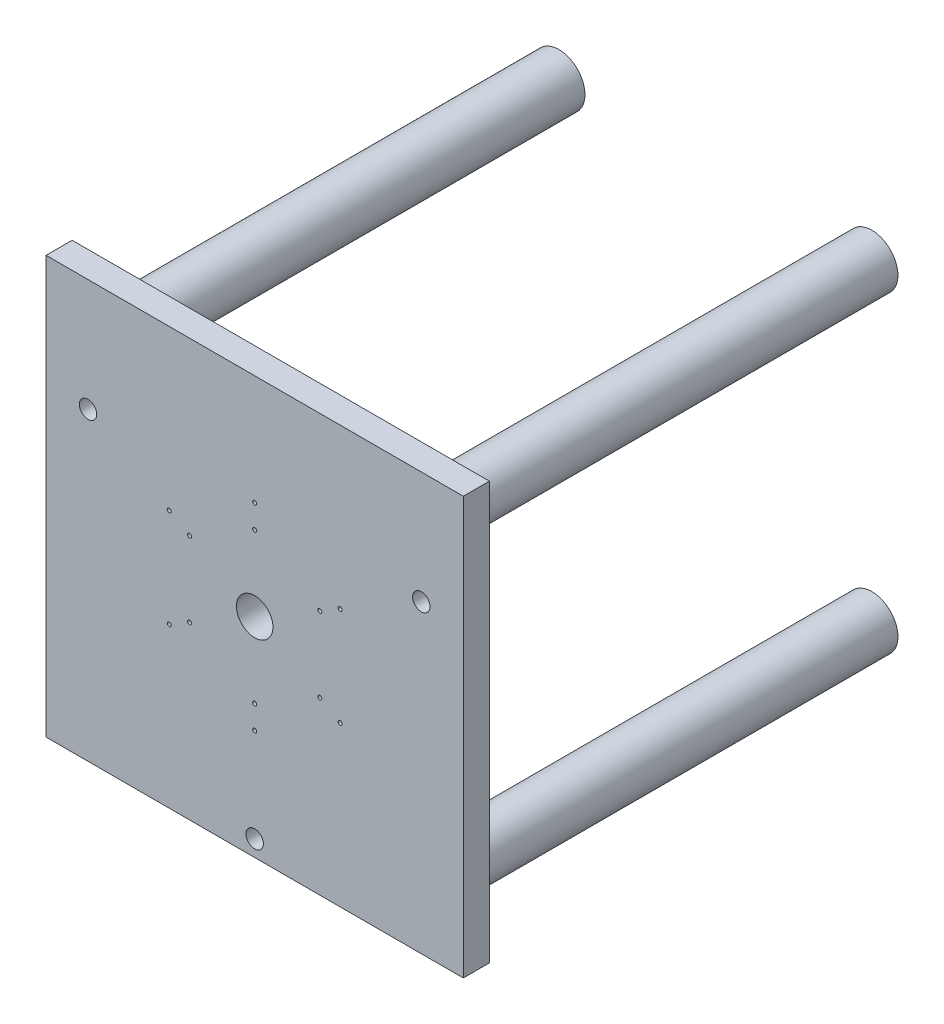
from build123d import *

# Parameters (mm, degrees)
SKETCH1_W               = 240
SKETCH1_H               = 240
BOSS_EXTRUDE1_DEPTH     = 15
SKETCH3_R               = 15
BOSS_EXTRUDE3_DEPTH     = 250
MIRROR7_COPY_1_SKETCH_R = 15
MIRROR7_COPY_1_DEPTH    = 250
SKETCH4_R               = 10.5
CUT_EXTRUDE1_DEPTH      = 250
SKETCH5_R               = 1.15
CUT_EXTRUDE2_DEPTH      = 40
MIRROR9_COPY_1_SKETCH_R = 1.15
MIRROR9_COPY_1_DEPTH    = 40
SKETCH6_R               = 5
CUT_EXTRUDE3_DEPTH      = 30


with BuildPart() as part:
    # Sketch1 → Boss-Extrude1 (new body)
    with BuildSketch(Plane.XY):
        Rectangle(SKETCH1_W, SKETCH1_H)
    extrude(amount=BOSS_EXTRUDE1_DEPTH)

    # Sketch3 → Boss-Extrude3 (add)
    with BuildSketch(Plane(origin=(0, 0, 0), x_dir=(-1, 0, 0), z_dir=(0, 0, -1))):
        with Locations((90, -90)):
            Circle(SKETCH3_R)
    boss_extrude3 = extrude(amount=BOSS_EXTRUDE3_DEPTH)

    # Mirror6: Boss-Extrude3 across plane
    add(boss_extrude3.mirror(Plane.ZX))

    # Mirror7: Boss-Extrude3 across plane
    add(boss_extrude3.mirror(Plane(origin=(0, 0, 0), x_dir=(0, 0, 1), z_dir=(1, 0, 0))))

    # Mirror7 copy 1 sketch → Mirror7 copy 1 (add)
    with BuildSketch(Plane(origin=(0, 0, 0), x_dir=(1, 0, 0), z_dir=(0, 0, -1))):
        with Locations((90, -90)):
            Circle(MIRROR7_COPY_1_SKETCH_R)
    extrude(amount=MIRROR7_COPY_1_DEPTH)

    # Sketch4 → Cut-Extrude1 (cut)
    with BuildSketch(Plane.XY.offset(15)):
        Circle(SKETCH4_R)
    extrude(amount=-CUT_EXTRUDE1_DEPTH, mode=Mode.SUBTRACT)

    # Sketch5 → Cut-Extrude2 (cut)
    with BuildSketch(Plane.XY.offset(15)):
        with Locations((37.455598714, 21.625)):
            Circle(SKETCH5_R)
        with Locations((49.146941665, 28.375)):
            Circle(SKETCH5_R)
        with Locations((0, 43.25)):
            Circle(SKETCH5_R)
        with Locations((0, 56.75)):
            Circle(SKETCH5_R)
    cut_extrude2 = extrude(amount=-CUT_EXTRUDE2_DEPTH, mode=Mode.SUBTRACT)

    # Mirror8: Cut-Extrude2 across plane
    add(cut_extrude2.mirror(Plane.ZX), mode=Mode.SUBTRACT)

    # Mirror9: Cut-Extrude2 across plane
    add(cut_extrude2.mirror(Plane(origin=(0, 0, 0), x_dir=(0, 0, 1), z_dir=(1, 0, 0))), mode=Mode.SUBTRACT)

    # Mirror9 copy 1 sketch → Mirror9 copy 1 (cut)
    with BuildSketch(Plane(origin=(0, 0, 15), x_dir=(-1, 0, 0), z_dir=(0, 0, 1))):
        with Locations((37.455598714, 21.625)):
            Circle(MIRROR9_COPY_1_SKETCH_R)
        with Locations((49.146941665, 28.375)):
            Circle(MIRROR9_COPY_1_SKETCH_R)
        with Locations((0, 43.25)):
            Circle(MIRROR9_COPY_1_SKETCH_R)
        with Locations((0, 56.75)):
            Circle(MIRROR9_COPY_1_SKETCH_R)
    extrude(amount=-MIRROR9_COPY_1_DEPTH, mode=Mode.SUBTRACT)

    # Sketch6 → Cut-Extrude3 (cut)
    with BuildSketch(Plane.XY.offset(15)):
        with Locations((0, -110.68)):
            Circle(SKETCH6_R)
        with Locations((-95.851691691, 55.34)):
            Circle(SKETCH6_R)
        with Locations((95.851691691, 55.34)):
            Circle(SKETCH6_R)
    extrude(amount=-CUT_EXTRUDE3_DEPTH, mode=Mode.SUBTRACT)


solid = part.part
